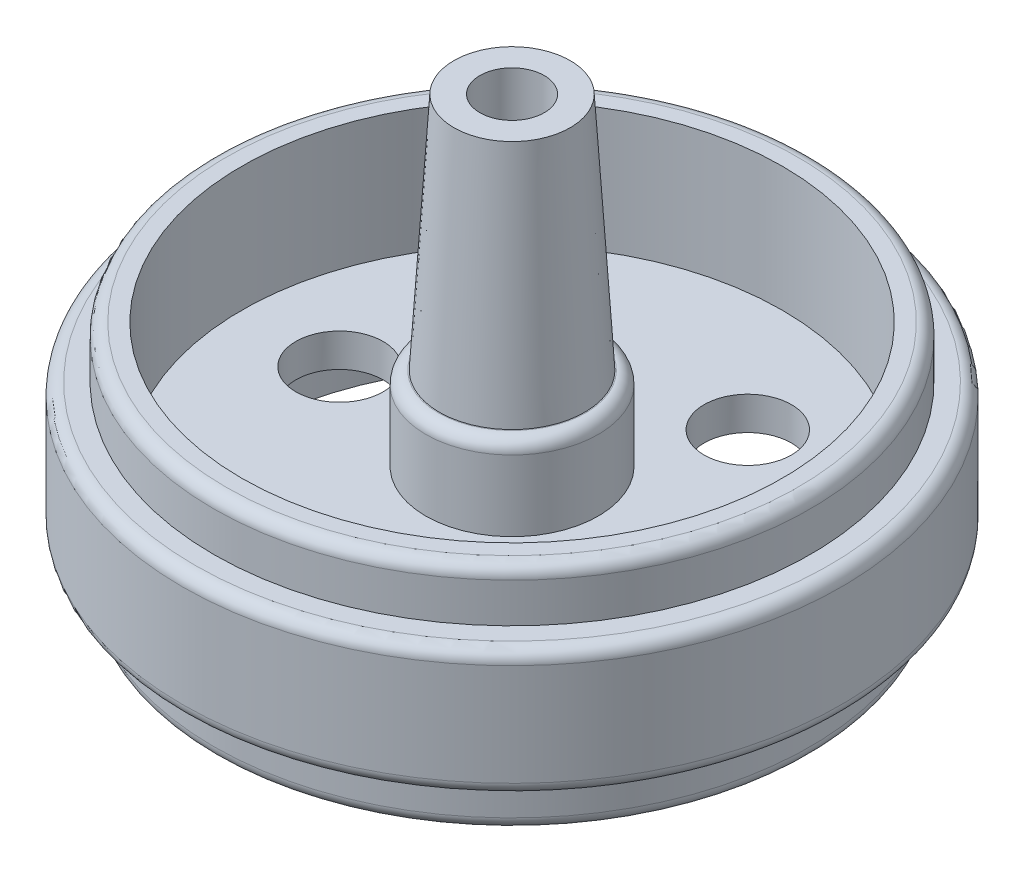
from build123d import *

# Parameters (mm, degrees)
SKETCH1_R           = 14.35
BOSS_EXTRUDE1_DEPTH = 2.5
SKETCH2_R           = 15.85
BOSS_EXTRUDE2_DEPTH = 6.1
SKETCH4_R           = 14.350000002
BOSS_EXTRUDE4_DEPTH = 2.5
SKETCH6_R           = 13
CUT_EXTRUDE1_DEPTH  = 6
SKETCH5_R           = 13.05
SKETCH5_R_2         = 4.3
CUT_EXTRUDE2_DEPTH  = 3.5
SKETCH7_R           = 4.15
BOSS_EXTRUDE5_DEPTH = 4
SKETCH8_R           = 3.5
BOSS_EXTRUDE6_DEPTH = 11.5
BOSS_EXTRUDE6_TAPER = 3.5
SKETCH9_R           = 3.25
CUT_EXTRUDE3_DEPTH  = 6.65
CUT_EXTRUDE4_REACH  = 22.6
SKETCH10_R          = 1.55
FILLET1_R           = 0.6
SKETCH11_R          = 2.1
CUT_EXTRUDE5_DEPTH  = 6.1


with BuildPart() as part:
    # Sketch1 → Boss-Extrude1 (new body)
    with BuildSketch(Plane(origin=(0, 0, 0), x_dir=(1, 0, 0), z_dir=(0, 1, 0))):
        Circle(SKETCH1_R)
    extrude(amount=BOSS_EXTRUDE1_DEPTH)

    # Sketch2 → Boss-Extrude2 (add)
    with BuildSketch(Plane(origin=(0, 2.5, 0), x_dir=(1, 0, 0), z_dir=(0, 1, 0))):
        Circle(SKETCH2_R)
    extrude(amount=BOSS_EXTRUDE2_DEPTH)

    # Sketch4 → Boss-Extrude4 (add)
    with BuildSketch(Plane(origin=(0, 8.6, 0), x_dir=(1, 0, 0), z_dir=(0, 1, 0))):
        Circle(SKETCH4_R)
    extrude(amount=BOSS_EXTRUDE4_DEPTH)

    # Sketch6 → Cut-Extrude1 (cut)
    with BuildSketch(Plane(origin=(0, 11.1, 0), x_dir=(1, 0, 0), z_dir=(0, 1, 0))):
        Circle(SKETCH6_R)
    extrude(amount=-CUT_EXTRUDE1_DEPTH, mode=Mode.SUBTRACT)

    # Sketch5 → Cut-Extrude2 (cut)
    with BuildSketch(Plane.XZ):
        Circle(SKETCH5_R)
        Circle(SKETCH5_R_2, mode=Mode.SUBTRACT)
    extrude(amount=-CUT_EXTRUDE2_DEPTH, mode=Mode.SUBTRACT)

    # Sketch7 → Boss-Extrude5 (add)
    with BuildSketch(Plane(origin=(0, 5.1, 0), x_dir=(1, 0, 0), z_dir=(0, 1, 0))):
        Circle(SKETCH7_R)
    extrude(amount=BOSS_EXTRUDE5_DEPTH)

    # Sketch8 → Boss-Extrude6 (add)
    with BuildSketch(Plane(origin=(0, 9.1, 0), x_dir=(1, 0, 0), z_dir=(0, 1, 0))):
        Circle(SKETCH8_R)
    extrude(amount=BOSS_EXTRUDE6_DEPTH, taper=BOSS_EXTRUDE6_TAPER)

    # Sketch9 → Cut-Extrude3 (cut)
    with BuildSketch(Plane.XZ):
        Circle(SKETCH9_R)
    extrude(amount=-CUT_EXTRUDE3_DEPTH, mode=Mode.SUBTRACT)

    # Sketch10 → Cut-Extrude4 (cut, up to next)
    with BuildSketch(Plane(origin=(0, 20.6, 0), x_dir=(1, 0, 0), z_dir=(0, 1, 0)), mode=Mode.PRIVATE) as cut_extrude4_sk1:
        Circle(SKETCH10_R)
    cut_extrude4_tool1 = extrude(cut_extrude4_sk1.sketch, amount=-CUT_EXTRUDE4_REACH, mode=Mode.PRIVATE) & part.part
    add(cut_extrude4_tool1.solids().sort_by_distance((0, 20.6, 0))[0], mode=Mode.SUBTRACT)

    # Fillet1
    fillet1_edges = [part.edges().sort_by_distance(p)[0] for p in [
        (-14.350000002, 11.1, 0),
        (-14.35, 0, 0),
        (-4.15, 9.1, 0),
        (-15.85, 2.5, 0),
        (-15.85, 8.6, 0),
    ]]
    fillet(fillet1_edges, radius=FILLET1_R)

    # Sketch11 → Cut-Extrude5 (cut, through all)
    with BuildSketch(Plane(origin=(0, 5.1, 0), x_dir=(1, 0, 0), z_dir=(0, 1, 0))):
        with Locations((-8.29999991, 0)):
            Circle(SKETCH11_R)
        with Locations((4.149999955, 7.188010773)):
            Circle(SKETCH11_R)
        with Locations((4.149999955, -7.188010773)):
            Circle(SKETCH11_R)
    extrude(amount=-CUT_EXTRUDE5_DEPTH, mode=Mode.SUBTRACT)


solid = part.part
